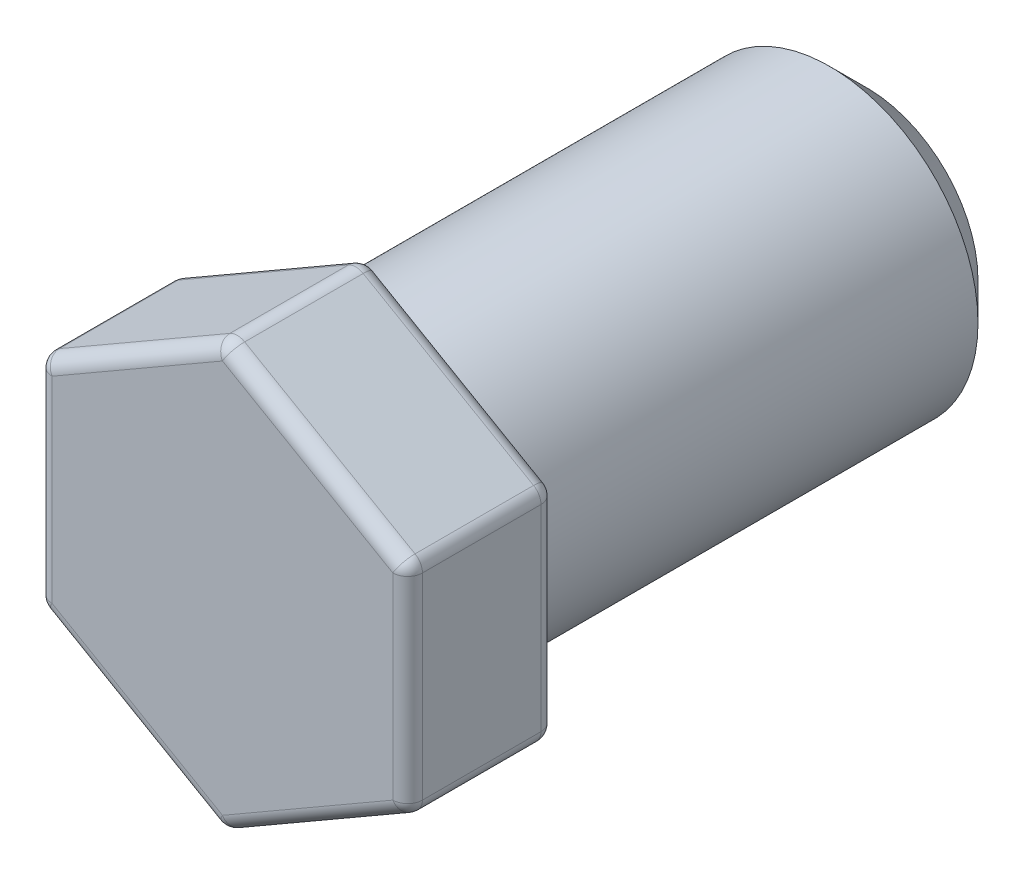
from build123d import *

# Parameters (mm, degrees)
SKETCH1_R           = 2
BOSS_EXTRUDE1_DEPTH = 3.35
BOSS_EXTRUDE2_DEPTH = 2
FILLET1_R           = 0.2
FILLET2_R           = 0.2
CHAMFER1_SIZE       = 0.5


with BuildPart() as part:
    # Sketch1 → Boss-Extrude1 (new body, symmetric)
    with BuildSketch(Plane.XY):
        Circle(SKETCH1_R)
    extrude(amount=BOSS_EXTRUDE1_DEPTH, both=True)

    # Sketch2 → Boss-Extrude2 (add)
    with BuildSketch(Plane.XY.offset(3.35)):
        Polygon((0, -2.886751346), (2.5, -1.443375673), (2.5, 1.443375673), (0, 2.886751346), (-2.5, 1.443375673), (-2.5, -1.443375673), align=None)
    extrude(amount=BOSS_EXTRUDE2_DEPTH)

    # Fillet1
    fillet1_edges = [part.edges().sort_by_distance(p)[0] for p in [
        (-2, 0, 3.35),
        (-1.25, -2.165063509, 3.35),
        (1.25, -2.165063509, 3.35),
        (2.5, 0, 3.35),
        (1.25, 2.165063509, 3.35),
        (-1.25, 2.165063509, 3.35),
        (-2.5, 0, 3.35),
        (-1.25, -2.165063509, 5.35),
        (1.25, -2.165063509, 5.35),
        (2.5, 0, 5.35),
        (1.25, 2.165063509, 5.35),
        (-1.25, 2.165063509, 5.35),
        (-2.5, 0, 5.35),
    ]]
    fillet(fillet1_edges, radius=FILLET1_R)

    # Fillet2
    fillet2_edges = [part.edges().sort_by_distance(p)[0] for p in [
        (-2.5, -1.443375673, 4.35),
        (-2.5, 1.443375673, 4.35),
        (0, 2.886751346, 4.35),
        (2.5, 1.443375673, 4.35),
        (2.5, -1.443375673, 4.35),
        (0, -2.886751346, 4.35),
        (2.436285816, 1.406590271, 5.29637683),
        (2.436285816, -1.406590271, 5.29637683),
        (0, 2.813180543, 5.29637683),
        (0, -2.813180543, 5.29637683),
        (-2.436285816, 1.406590271, 5.29637683),
        (-2.436285816, -1.406590271, 5.29637683),
        (-2.436285816, 1.406590271, 3.40362317),
        (0, 2.813180543, 3.40362317),
        (-2.436285816, -1.406590271, 3.40362317),
        (2.436285816, 1.406590271, 3.40362317),
        (0, -2.813180543, 3.40362317),
        (2.436285816, -1.406590271, 3.40362317),
    ]]
    fillet(fillet2_edges, radius=FILLET2_R)

    # Chamfer1
    chamfer1_edges = [part.edges().sort_by_distance(p)[0] for p in [
        (-2, 0, -3.35),
    ]]
    chamfer(chamfer1_edges, length=CHAMFER1_SIZE)


solid = part.part
